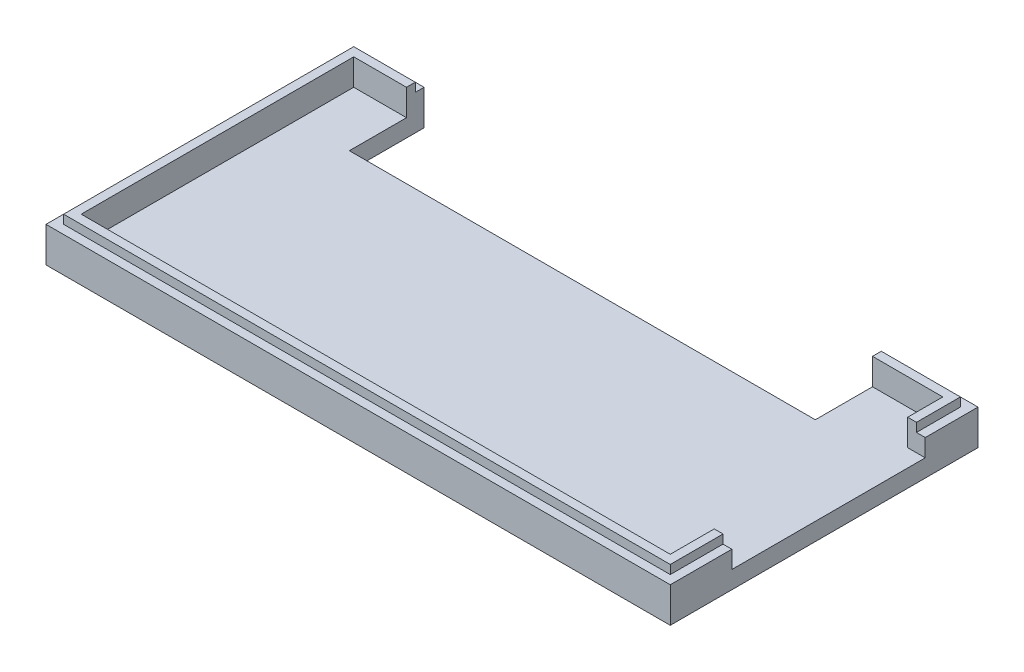
from build123d import *

# Parameters (mm, degrees)
SKETCH1_W           = 71
SKETCH1_H           = 35
BOSS_EXTRUDE1_DEPTH = 2
SKETCH2_W           = 71
SKETCH2_H           = 35
SKETCH2_W_2         = 67
SKETCH2_H_2         = 31
BOSS_EXTRUDE2_DEPTH = 2
SKETCH3_W           = 69
SKETCH3_H           = 33
SKETCH3_W_2         = 67
SKETCH3_H_2         = 31
BOSS_EXTRUDE3_DEPTH = 1
SKETCH4_W           = 22
SKETCH4_H           = 3
CUT_EXTRUDE1_DEPTH  = 5
SKETCH5_W           = 53
SKETCH5_H           = 8.5
CUT_EXTRUDE2_DEPTH  = 5


with BuildPart() as part:
    # Sketch1 → Boss-Extrude1 (new body)
    with BuildSketch(Plane(origin=(0, 0, 0), x_dir=(1, 0, 0), z_dir=(0, 1, 0))):
        with Locations((33.5, 15.5)):
            Rectangle(SKETCH1_W, SKETCH1_H)
    extrude(amount=BOSS_EXTRUDE1_DEPTH)

    # Sketch2 → Boss-Extrude2 (add)
    with BuildSketch(Plane(origin=(0, 2, 0), x_dir=(1, 0, 0), z_dir=(0, 1, 0))):
        with Locations((33.5, 15.5)):
            Rectangle(SKETCH2_W, SKETCH2_H)
        with Locations((33.5, 15.5)):
            Rectangle(SKETCH2_W_2, SKETCH2_H_2, mode=Mode.SUBTRACT)
    extrude(amount=BOSS_EXTRUDE2_DEPTH)

    # Sketch3 → Boss-Extrude3 (add)
    with BuildSketch(Plane(origin=(0, 4, 0), x_dir=(1, 0, 0), z_dir=(0, 1, 0))):
        with Locations((33.5, 15.5)):
            Rectangle(SKETCH3_W, SKETCH3_H)
        with Locations((33.5, 15.5)):
            Rectangle(SKETCH3_W_2, SKETCH3_H_2, mode=Mode.SUBTRACT)
    extrude(amount=BOSS_EXTRUDE3_DEPTH)

    # Sketch4 → Cut-Extrude1 (cut)
    with BuildSketch(Plane.ZY.offset(-67)):
        with Locations((-16, 3.5)):
            Rectangle(SKETCH4_W, SKETCH4_H)
    extrude(amount=-CUT_EXTRUDE1_DEPTH, mode=Mode.SUBTRACT)

    # Sketch5 → Cut-Extrude2 (cut)
    with BuildSketch(Plane.XZ):
        with Locations((32.5, -28.75)):
            Rectangle(SKETCH5_W, SKETCH5_H)
    extrude(amount=-CUT_EXTRUDE2_DEPTH, mode=Mode.SUBTRACT)


solid = part.part
